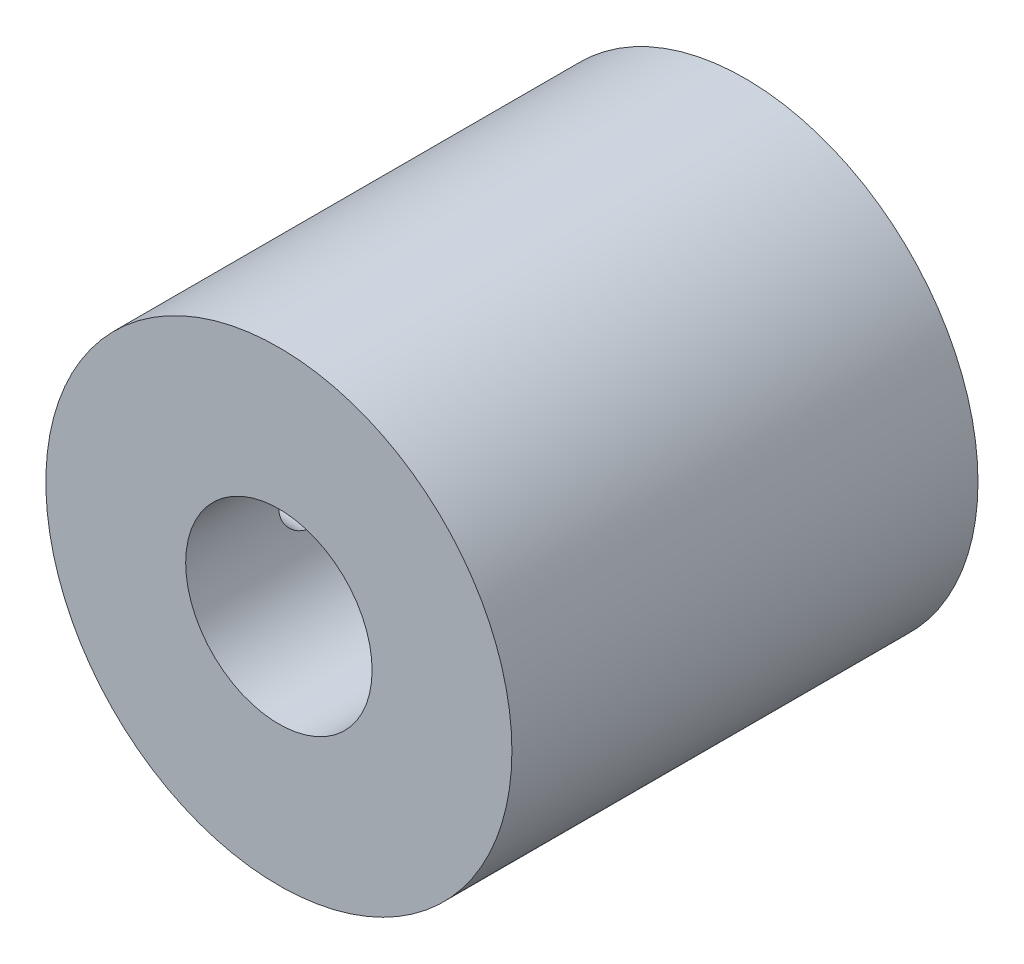
from build123d import *

# Parameters (mm, degrees)
CROQUIS1_R              = 12.5
SALIENTE_EXTRUIR1_DEPTH = 12.5
CROQUIS2_R              = 5
CORTAR_EXTRUIR1_DEPTH   = 25
CORTAR_EXTRUIR2_REACH   = 14.5
CROQUIS3_R              = 1.5


with BuildPart() as part:
    # Croquis1 → Saliente-Extruir1 (new body, symmetric)
    with BuildSketch(Plane.XY):
        Circle(CROQUIS1_R)
    extrude(amount=SALIENTE_EXTRUIR1_DEPTH, both=True)

    # Croquis2 → Cortar-Extruir1 (cut)
    with BuildSketch(Plane.XY.offset(12.5)):
        Circle(CROQUIS2_R)
    extrude(amount=-CORTAR_EXTRUIR1_DEPTH, mode=Mode.SUBTRACT)

    # Croquis3 → Cortar-Extruir2 (cut, up to next)
    with BuildSketch(Plane(origin=(0, 0, 0), x_dir=(0, 0, -1), z_dir=(1, 0, 0)), mode=Mode.PRIVATE) as cortar_extruir2_sk1:
        with Locations((-6, 0)):
            Circle(CROQUIS3_R)
    cortar_extruir2_tool1 = extrude(cortar_extruir2_sk1.sketch, amount=-CORTAR_EXTRUIR2_REACH, mode=Mode.PRIVATE) & part.part
    add(cortar_extruir2_tool1.solids().sort_by_distance((0, 0, 6))[0], mode=Mode.SUBTRACT)
    # Croquis3 → Cortar-Extruir2 (cut, up to next)
    with BuildSketch(Plane(origin=(0, 0, 0), x_dir=(0, 0, -1), z_dir=(1, 0, 0)), mode=Mode.PRIVATE) as cortar_extruir2_sk2:
        with Locations((6, 0)):
            Circle(CROQUIS3_R)
    cortar_extruir2_tool2 = extrude(cortar_extruir2_sk2.sketch, amount=-CORTAR_EXTRUIR2_REACH, mode=Mode.PRIVATE) & part.part
    add(cortar_extruir2_tool2.solids().sort_by_distance((0, 0, -6))[0], mode=Mode.SUBTRACT)


solid = part.part
